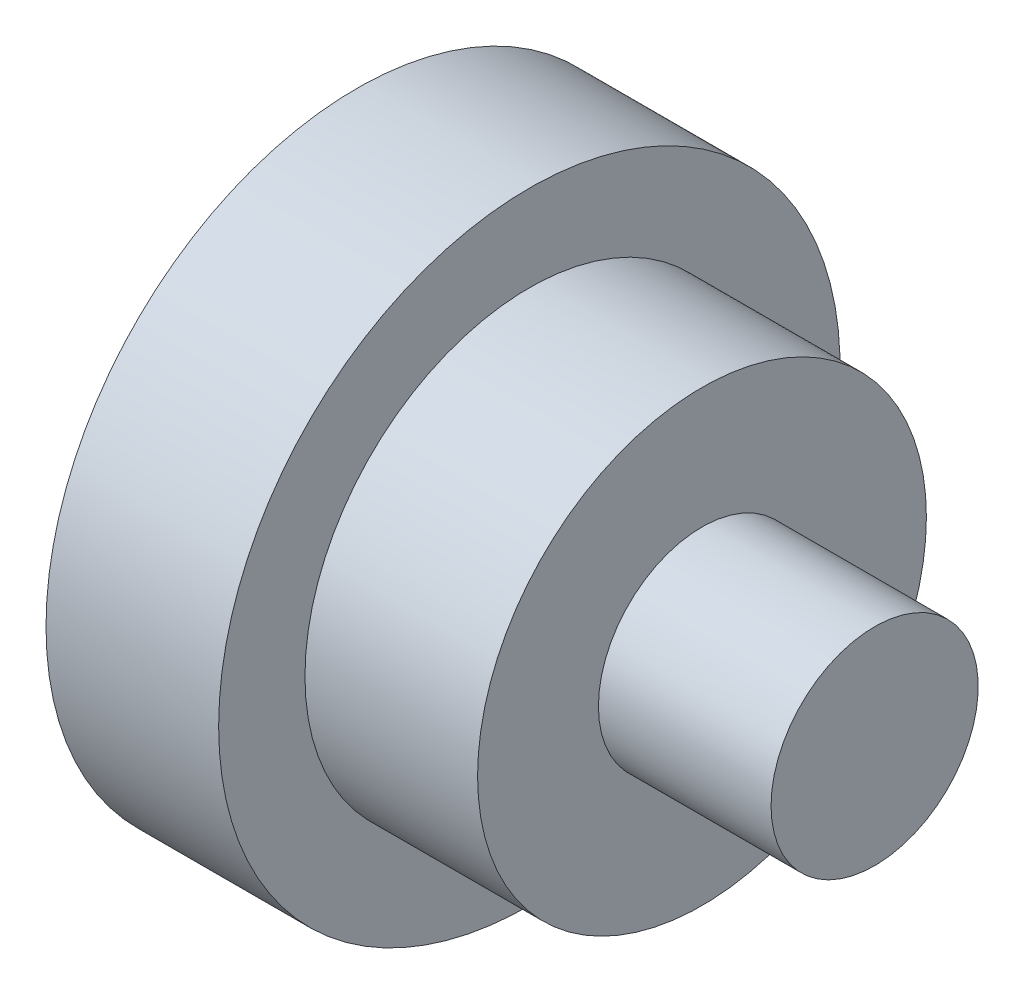
from build123d import *

# Parameters (mm, degrees)
SKETCH_3_R          = 9
EXTRUDE_1_DEPTH     = 5
SKETCH_4_R          = 5
CUT_EXTRUDE_1_DEPTH = 8


with BuildPart() as part:
    # 草图2 → 旋转1 (revolve)
    with BuildSketch(Plane.XY):
        Polygon((0, 0), (0, 6.5), (5, 6.5), (5, 3), (10, 3), (10, 0), align=None)
    revolve(axis=Axis((0, 0, 0), (1, 0, 0)))

    # 草图3 → 凸台-拉伸1 (add)
    with BuildSketch(Plane.ZY):
        Circle(SKETCH_3_R)
    extrude(amount=EXTRUDE_1_DEPTH)

    # 草图4 → 切除-拉伸1 (cut)
    with BuildSketch(Plane.ZY.offset(5)):
        Circle(SKETCH_4_R)
    extrude(amount=-CUT_EXTRUDE_1_DEPTH, mode=Mode.SUBTRACT)


solid = part.part
